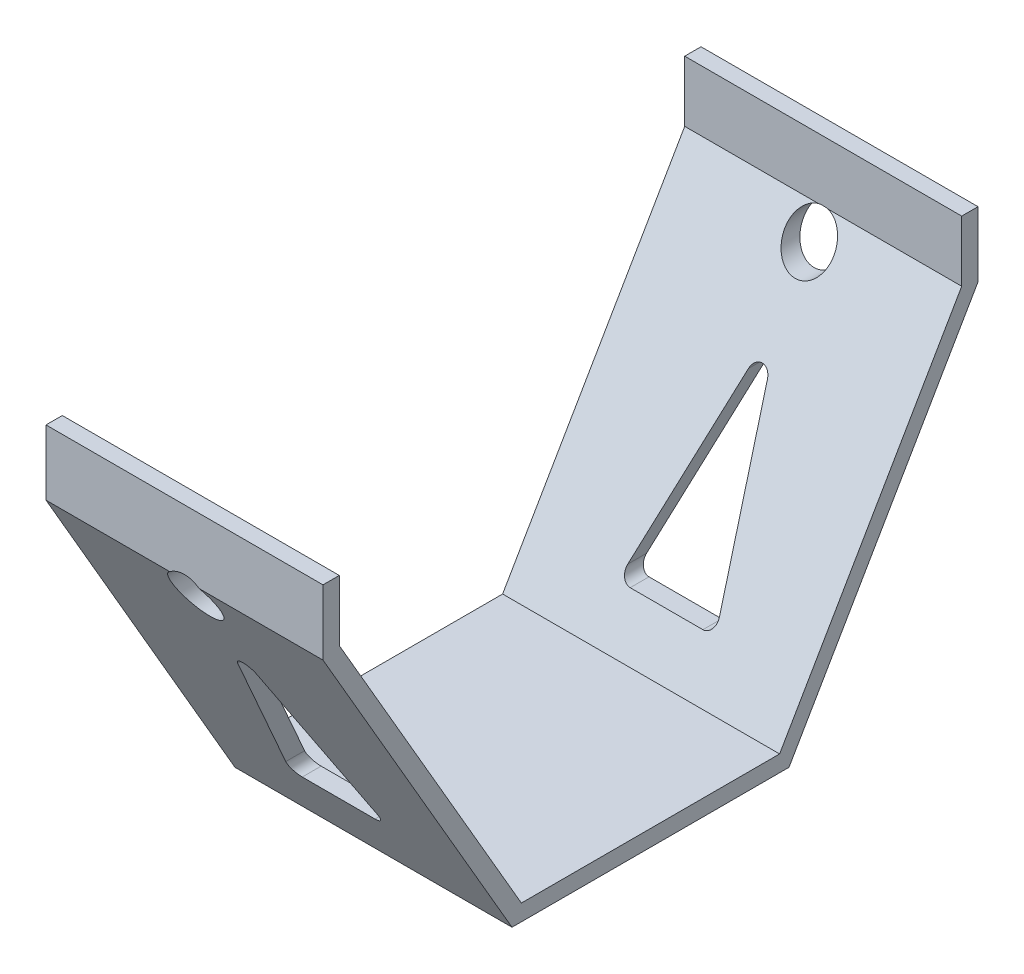
from build123d import *

# Parameters (mm, degrees)
EXTRUDE_1_DEPTH          = 42.5
SKETCH_3_R               = 15
EXTRUDE_2_DEPTH          = 22
CUT_EXTRUDE_1_DEPTH      = 101.5
CUT_EXTRUDE_1_DEPTH_BACK = 101.5
FILLET_1_R               = 3
SKETCH_5_R               = 7.5
CUT_EXTRUDE_2_DEPTH      = 202


with BuildPart() as part:
    # 草图1 → 凸台-拉伸1 (new body, symmetric)
    with BuildSketch(Plane(origin=(0, 0, 0), x_dir=(0, 0, -1), z_dir=(1, 0, 0))):
        Polygon((-100.5, 100), (-42.5, 0), (42.5, 0), (100.5, 100), (100.5, 120), (95.5, 120), (95.5, 115), (95.5, 101.345066218), (39.619861593, 5), (-39.619861593, 5), (-95.5, 101.345066218), (-95.5, 115), (-95.5, 120), (-100.5, 120), align=None)
    extrude(amount=EXTRUDE_1_DEPTH, both=True)

    # 草图3 → 凸台-拉伸2 (add)
    with BuildSketch(Plane.XZ):
        Circle(SKETCH_3_R)
    extrude(amount=EXTRUDE_2_DEPTH)

    # 草图4 → 切除-拉伸1 (cut, two sides)
    with BuildSketch(Plane.XY) as cut_extrude_1_sk:
        Polygon((0, 78.450873214), (-15, 18.450873214), (15, 18.450873214), align=None)
    extrude(amount=CUT_EXTRUDE_1_DEPTH, mode=Mode.SUBTRACT)
    extrude(cut_extrude_1_sk.sketch, amount=-CUT_EXTRUDE_1_DEPTH_BACK, mode=Mode.SUBTRACT)

    # 圆角1
    fillet_1_edges = [part.edges().sort_by_distance(p)[0] for p in [
        (0, 78.450873214, -85.111437261),
        (0, 78.450873214, 85.111437261),
        (15, 18.450873214, -50.311437261),
        (15, 18.450873214, 50.311437261),
        (-15, 18.450873214, -50.311437261),
        (-15, 18.450873214, 50.311437261),
    ]]
    fillet(fillet_1_edges, radius=FILLET_1_R)

    # 草图5 → 切除-拉伸2 (cut, through all)
    with BuildSketch(Plane.XY.offset(100.5)):
        with Locations((0, 94)):
            Circle(SKETCH_5_R)
    extrude(amount=-CUT_EXTRUDE_2_DEPTH, mode=Mode.SUBTRACT)


solid = part.part
